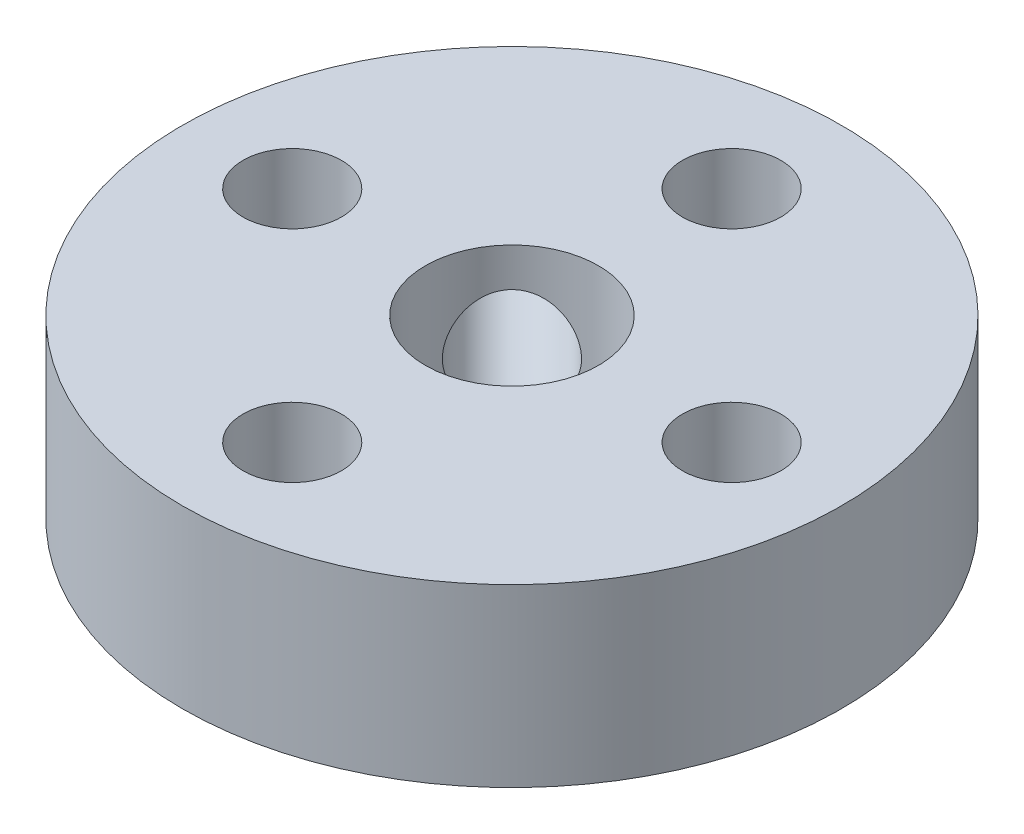
from build123d import *

# Parameters (mm, degrees)
SKETCH2_R           = 9.525
SKETCH2_R_2         = 1.4224
SKETCH2_R_3         = 2.5
BOSS_EXTRUDE1_DEPTH = 5.08
CUT_EXTRUDE1_REACH  = 15.47
SKETCH7_R           = 1.4224


with BuildPart() as part:
    # Sketch2 → Boss-Extrude1 (new body)
    with BuildSketch(Plane(origin=(0, 0, 0), x_dir=(1, 0, 0), z_dir=(0, 1, 0))):
        Circle(SKETCH2_R)
        with Locations((0, 6.35)):
            Circle(SKETCH2_R_2, mode=Mode.SUBTRACT)
        with Locations((6.35, 0)):
            Circle(SKETCH2_R_2, mode=Mode.SUBTRACT)
        with Locations((0, -6.35)):
            Circle(SKETCH2_R_2, mode=Mode.SUBTRACT)
        with Locations((-6.35, 0)):
            Circle(SKETCH2_R_2, mode=Mode.SUBTRACT)
        Circle(SKETCH2_R_3, mode=Mode.SUBTRACT)
    extrude(amount=BOSS_EXTRUDE1_DEPTH)

    # Sketch7 → Cut-Extrude1 (cut, up to next)
    with BuildSketch(Plane(origin=(0, 0, 0), x_dir=(0.707106781, 0, -0.707106781), z_dir=(0.707106781, 0, 0.707106781)), mode=Mode.PRIVATE) as cut_extrude1_sk1:
        with Locations((0, 2.54)):
            Circle(SKETCH7_R)
    cut_extrude1_tool1 = extrude(cut_extrude1_sk1.sketch, amount=-CUT_EXTRUDE1_REACH, mode=Mode.PRIVATE) & part.part
    add(cut_extrude1_tool1.solids().sort_by_distance((0, 2.54, 0))[0], mode=Mode.SUBTRACT)


solid = part.part
